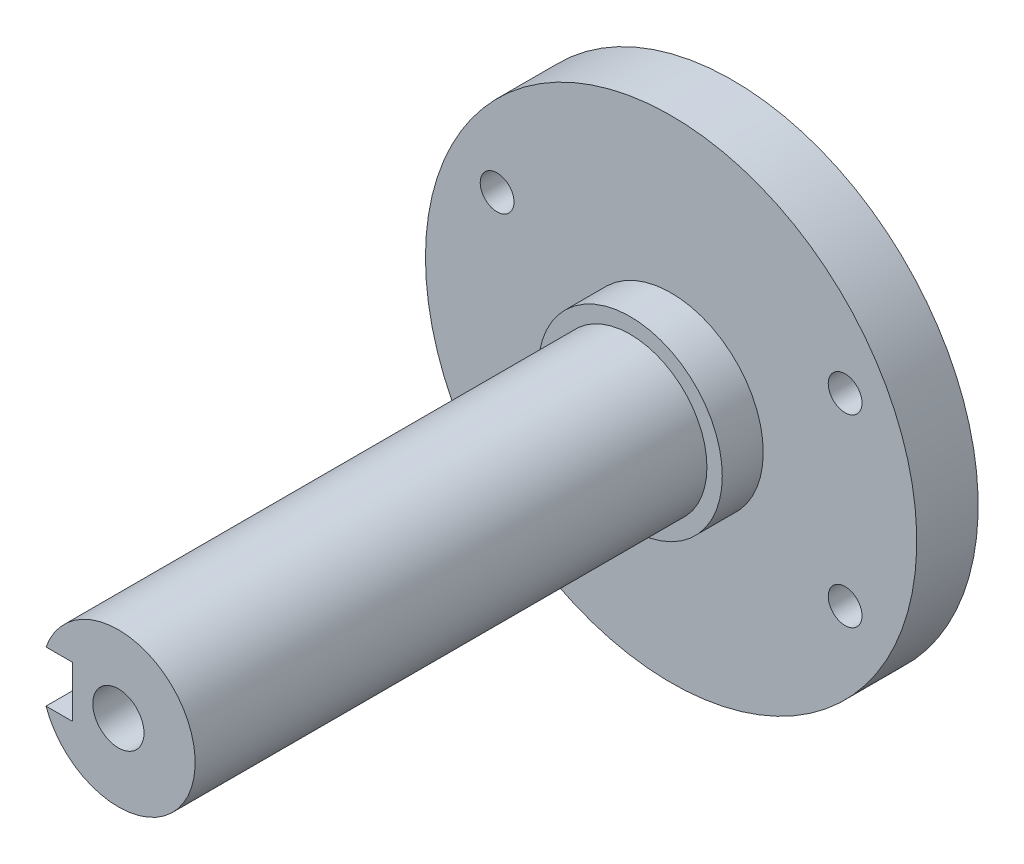
from build123d import *

# Parameters (mm, degrees)
ESQUISSE1_R                                   = 9
BOSS_EXTRU_1_DEPTH                            = 4
ESQUISSE2_R                                   = 24
BOSS_EXTRU_2_DEPTH                            = 6
ESQUISSE7_R                                   = 7.5
BOSS_EXTRU_3_DEPTH                            = 50
TROU_POUR_TARAUDAGE_POUR_TROU_TARAUD_M4_D     = 3.3
TROU_POUR_TARAUDAGE_POUR_TROU_TARAUD_M4_DEPTH = 6
TROU_POUR_TARAUDAGE_POUR_TROU_TARAUD_M4_TIP   = 0.991420021
ENL_V_MAT_EXTRU_1_DEPTH                       = 3
TROU_POUR_TARAUDAGE_POUR_TROU_TARAUD_M6_D     = 5
TROU_POUR_TARAUDAGE_POUR_TROU_TARAUD_M6_DEPTH = 15
TROU_POUR_TARAUDAGE_POUR_TROU_TARAUD_M6_TIP   = 1.502151548


with BuildPart() as part:
    # Esquisse1 → Boss.-Extru.1 (new body)
    with BuildSketch(Plane.XY):
        Circle(ESQUISSE1_R)
    extrude(amount=BOSS_EXTRU_1_DEPTH)

    # Esquisse2 → Boss.-Extru.2 (add)
    with BuildSketch(Plane(origin=(0, 0, 0), x_dir=(-1, 0, 0), z_dir=(0, 0, -1))):
        Circle(ESQUISSE2_R)
    extrude(amount=BOSS_EXTRU_2_DEPTH)

    # Esquisse7 → Boss.-Extru.3 (add)
    with BuildSketch(Plane.XY.offset(4)):
        Circle(ESQUISSE7_R)
    extrude(amount=BOSS_EXTRU_3_DEPTH)

    # Trou pour taraudage pour trou taraudé M42
    with Locations(Plane(origin=(0, 0, -6), x_dir=(-1, 0, 0), z_dir=(0, 0, -1))):
        with Locations((-17, 9), (17, -9), (17, 9), (-17, -9)):
            Hole(TROU_POUR_TARAUDAGE_POUR_TROU_TARAUD_M4_D / 2, depth=TROU_POUR_TARAUDAGE_POUR_TROU_TARAUD_M4_DEPTH)
            with Locations((0, 0, -(TROU_POUR_TARAUDAGE_POUR_TROU_TARAUD_M4_DEPTH + TROU_POUR_TARAUDAGE_POUR_TROU_TARAUD_M4_TIP / 2))):  # 118° drill point
                Cone(0, TROU_POUR_TARAUDAGE_POUR_TROU_TARAUD_M4_D / 2, TROU_POUR_TARAUDAGE_POUR_TROU_TARAUD_M4_TIP, mode=Mode.SUBTRACT)

    # Esquisse10 → Enlèv. mat.-Extru.1 (cut)
    with BuildSketch(Plane.ZY.offset(7.5)):
        with BuildLine():
            Line((79, -2.5), (29, -2.5))
            ThreePointArc((29, -2.5), (26.5, 0), (29, 2.5))
            Line((29, 2.5), (79, 2.5))
            ThreePointArc((79, 2.5), (81.5, 0), (79, -2.5))
        make_face()
    extrude(amount=-ENL_V_MAT_EXTRU_1_DEPTH, mode=Mode.SUBTRACT)

    # Trou pour taraudage pour trou taraudé M61
    with Locations(Plane.XY.offset(54)):
        with Locations((0, 0)):
            Hole(TROU_POUR_TARAUDAGE_POUR_TROU_TARAUD_M6_D / 2, depth=TROU_POUR_TARAUDAGE_POUR_TROU_TARAUD_M6_DEPTH)
            with Locations((0, 0, -(TROU_POUR_TARAUDAGE_POUR_TROU_TARAUD_M6_DEPTH + TROU_POUR_TARAUDAGE_POUR_TROU_TARAUD_M6_TIP / 2))):  # 118° drill point
                Cone(0, TROU_POUR_TARAUDAGE_POUR_TROU_TARAUD_M6_D / 2, TROU_POUR_TARAUDAGE_POUR_TROU_TARAUD_M6_TIP, mode=Mode.SUBTRACT)


solid = part.part
